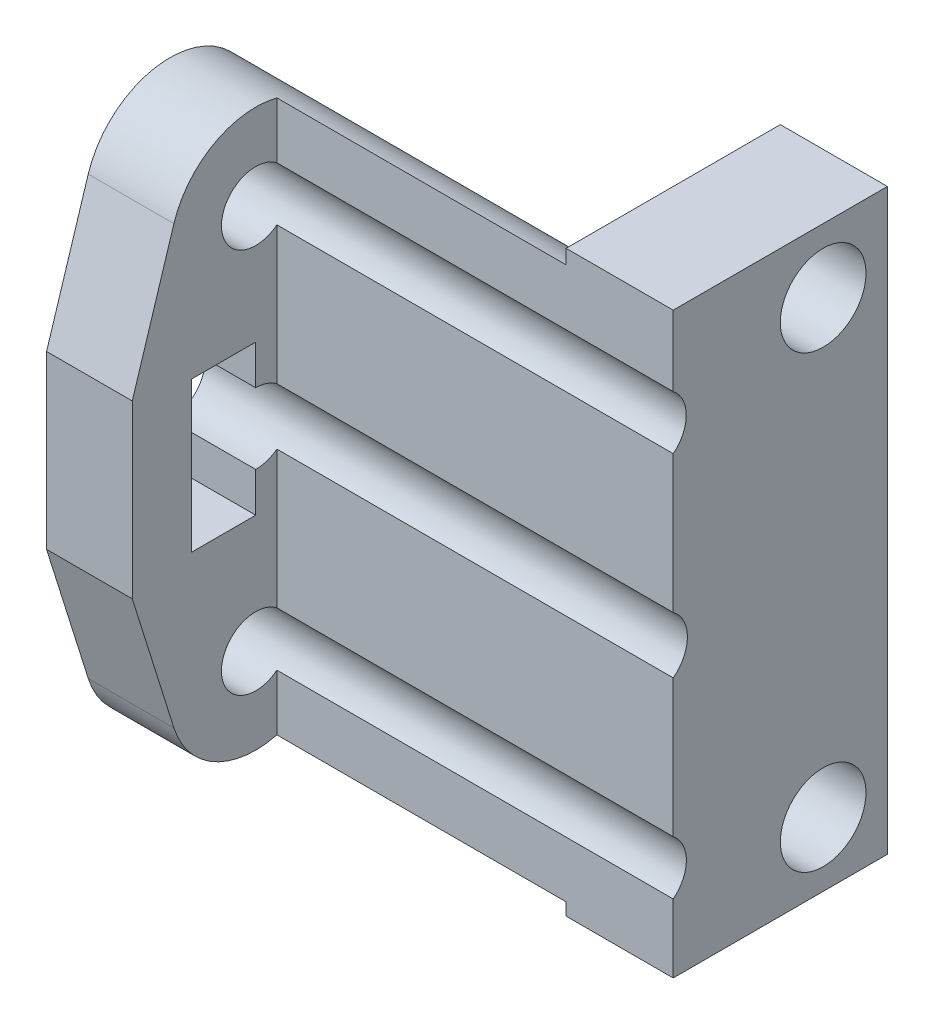
from build123d import *

# Parameters (mm, degrees)
ESBO_O1_W                     = 5
ESBO_O1_H                     = 27
RESSALTO_EXTRUS_O1_DEPTH      = 4
RESSALTO_EXTRUS_O1_DEPTH_BACK = 6
ESBO_O2_W                     = 4
ESBO_O2_H                     = 27
RESSALTO_EXTRUS_O2_DEPTH      = 17.5
ESBO_O3_W                     = 4
ESBO_O3_H                     = 27
RESSALTO_EXTRUS_O3_DEPTH      = 6.75232
CORTE_EXTRUS_O1_DEPTH         = 17.5
ESBO_O5_R                     = 1.598160281
ESBO_O5_R_2                   = 1.600993429
CORTE_EXTRUS_O2_DEPTH         = 23.5
ESBO_O6_R                     = 2
CORTE_EXTRUS_O3_DEPTH         = 14


with BuildPart() as part:
    # Esboço1 → Ressalto-extrusão1 (new body, two sides)
    with BuildSketch(Plane.XY) as ressalto_extrus_o1_sk:
        with Locations((2.5, 202.468429513)):
            Rectangle(ESBO_O1_W, ESBO_O1_H)
    extrude(amount=RESSALTO_EXTRUS_O1_DEPTH)
    extrude(ressalto_extrus_o1_sk.sketch, amount=-RESSALTO_EXTRUS_O1_DEPTH_BACK)

    # Esboço2 → Ressalto-extrusão2 (add)
    with BuildSketch(Plane.ZY):
        with Locations((2, 202.468429513)):
            Rectangle(ESBO_O2_W, ESBO_O2_H)
    extrude(amount=RESSALTO_EXTRUS_O2_DEPTH)

    # Esboço3 → Ressalto-extrusão3 (add)
    with BuildSketch(Plane.XY.offset(4)):
        with Locations((-15.5, 202.468429513)):
            Rectangle(ESBO_O3_W, ESBO_O3_H)
    extrude(amount=RESSALTO_EXTRUS_O3_DEPTH)

    # Esboço4 → Corte-extrusão1 (cut)
    with BuildSketch(Plane.ZY.offset(17.5)):
        with BuildLine():
            Line((10.752320108, 206.42333876), (10.752320108, 215.968429513))
            Line((10.752320108, 215.968429513), (0, 215.968429513))
            Line((0, 215.968429513), (0, 208.891636686))
            Line((0, 208.891636686), (1.172017461, 212.62112057))
            ThreePointArc((1.172017461, 212.62112057), (4.990885368, 215.423316276), (8.808422699, 212.619308145))
            Line((8.808422699, 212.619308145), (10.752320108, 206.42333876))
        make_face()
        with BuildLine():
            Line((10.752320108, 198.42333838), (10.752320108, 188.968429513))
            Line((10.752320108, 188.968429513), (0, 188.968429513))
            Line((0, 188.968429513), (0, 195.95406786))
            Line((0, 195.95406786), (1.171653646, 192.22427259))
            ThreePointArc((1.171653646, 192.22427259), (4.988209463, 189.422715847), (8.804822441, 192.224194718))
            Line((8.804822441, 192.224194718), (10.752320108, 198.42333838))
        make_face()
    extrude(amount=-CORTE_EXTRUS_O1_DEPTH, mode=Mode.SUBTRACT)

    # Esboço5 → Corte-extrusão2 (cut, through all)
    with BuildSketch(Plane.ZY.offset(17.5)):
        with Locations((4.989935533, 211.421312021)):
            Circle(ESBO_O5_R)
        with Locations((4.988250275, 193.423193451)):
            Circle(ESBO_O5_R_2)
        with BuildLine():
            Line((4.9893193, 200.772419725), (4.9893193, 198.92333857))
            Line((4.9893193, 198.92333857), (7.9893193, 198.92333857))
            Line((7.9893193, 198.92333857), (7.9893193, 205.92333857))
            Line((7.9893193, 205.92333857), (4.9893193, 205.92333857))
            Line((4.9893193, 205.92333857), (4.9893193, 204.074257415))
            ThreePointArc((4.9893193, 204.074257415), (3.338400455, 202.42333857), (4.9893193, 200.772419725))
        make_face()
    extrude(amount=-CORTE_EXTRUS_O2_DEPTH, mode=Mode.SUBTRACT)

    # Esboço6 → Corte-extrusão3 (cut)
    with BuildSketch(Plane.ZY):
        with Locations((-3, 212.968429513)):
            Circle(ESBO_O6_R)
        with Locations((-3, 191.968429513)):
            Circle(ESBO_O6_R)
    extrude(amount=-CORTE_EXTRUS_O3_DEPTH, mode=Mode.SUBTRACT)


solid = part.part
